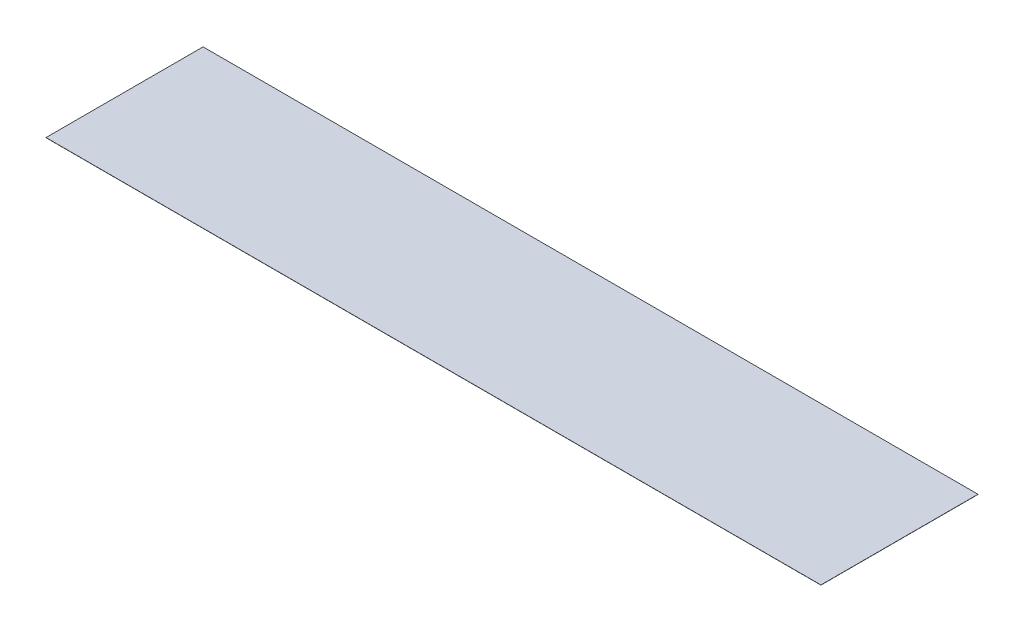
from build123d import *

# Parameters (mm, degrees)
SKETCH1_W           = 22555.2
SKETCH1_H           = 4572
BOSS_EXTRUDE1_DEPTH = 4.7752


with BuildPart() as part:
    # Sketch1 → Boss-Extrude1 (new body)
    with BuildSketch(Plane(origin=(0, 0, 0), x_dir=(1, 0, 0), z_dir=(0, 1, 0))):
        with Locations((0, 2286)):
            Rectangle(SKETCH1_W, SKETCH1_H)
    extrude(amount=BOSS_EXTRUDE1_DEPTH)


solid = part.part
